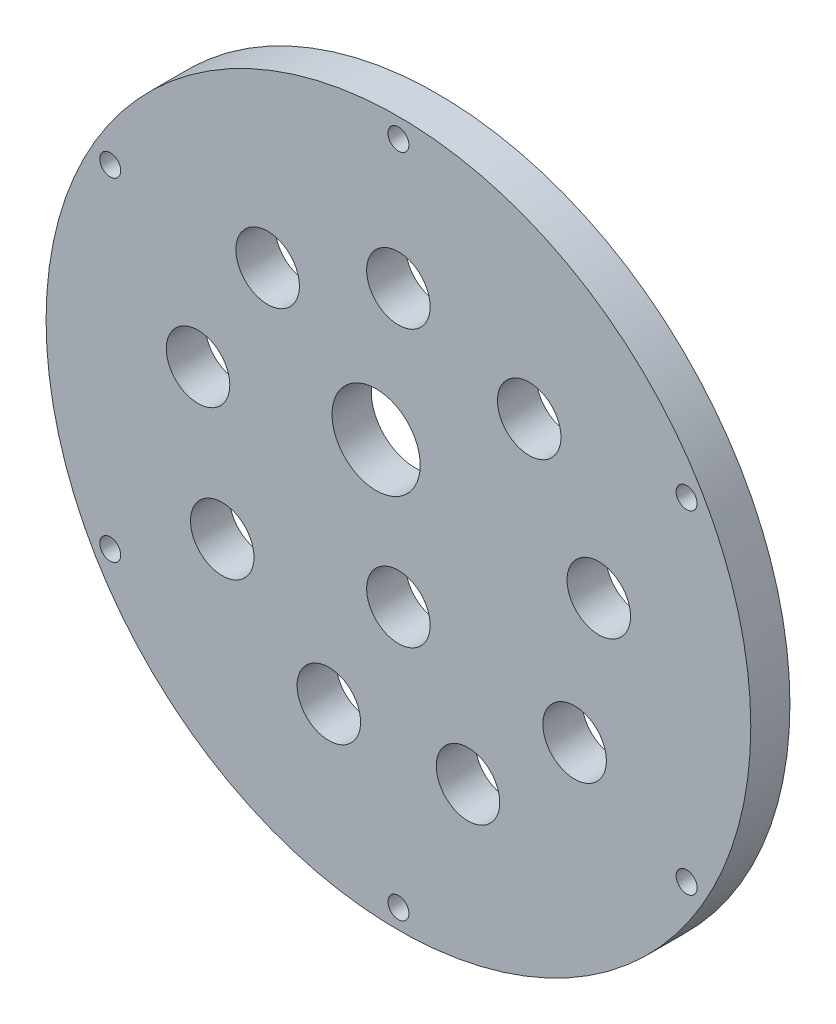
from build123d import *

# Parameters (mm, degrees)
SKETCH2_R           = 57.15
BOSS_EXTRUDE1_DEPTH = 6.35
SKETCH3_R           = 5.15
CUT_EXTRUDE1_DEPTH  = 7.35
CIRPATTERN1_COUNT   = 9
SKETCH6_R           = 1.7
CUT_EXTRUDE4_DEPTH  = 7.35
CIRPATTERN3_COUNT   = 6
SKETCH7_R           = 7.15
SKETCH7_R_2         = 5.15
CUT_EXTRUDE5_DEPTH  = 7.35


with BuildPart() as part:
    # Sketch2 → Boss-Extrude1 (new body)
    with BuildSketch(Plane.XY):
        Circle(SKETCH2_R)
    extrude(amount=BOSS_EXTRUDE1_DEPTH)

    # Sketch3 → Cut-Extrude1 (cut, through all)
    with BuildSketch(Plane.XY.offset(6.35)):
        with Locations((0, 33)):
            Circle(SKETCH3_R)
    cut_extrude1 = extrude(amount=-CUT_EXTRUDE1_DEPTH, mode=Mode.SUBTRACT)

    # CirPattern1: Cut-Extrude1 ×9 about axis
    cirpattern1_axis = Axis((0, 0, 0), (0, 0, 1))
    for i in range(1, CIRPATTERN1_COUNT):
        add(cut_extrude1.rotate(cirpattern1_axis, i * 360 / CIRPATTERN1_COUNT), mode=Mode.SUBTRACT)

    # Sketch6 → Cut-Extrude4 (cut, through all)
    with BuildSketch(Plane.XY.offset(6.35)):
        with Locations((0, 53.975)):
            Circle(SKETCH6_R)
    cut_extrude4 = extrude(amount=-CUT_EXTRUDE4_DEPTH, mode=Mode.SUBTRACT)

    # CirPattern3: Cut-Extrude4 ×6 about axis
    cirpattern3_axis = Axis((0, 0, 0), (0, 0, 1))
    for i in range(1, CIRPATTERN3_COUNT):
        add(cut_extrude4.rotate(cirpattern3_axis, i * 360 / CIRPATTERN3_COUNT), mode=Mode.SUBTRACT)

    # Sketch7 → Cut-Extrude5 (cut, through all)
    with BuildSketch(Plane.XY.offset(6.35)):
        with Locations((-3.616187958, 9.935394759)):
            Circle(SKETCH7_R)
        with Locations((0, -11.752952649)):
            Circle(SKETCH7_R_2)
    extrude(amount=-CUT_EXTRUDE5_DEPTH, mode=Mode.SUBTRACT)


solid = part.part
